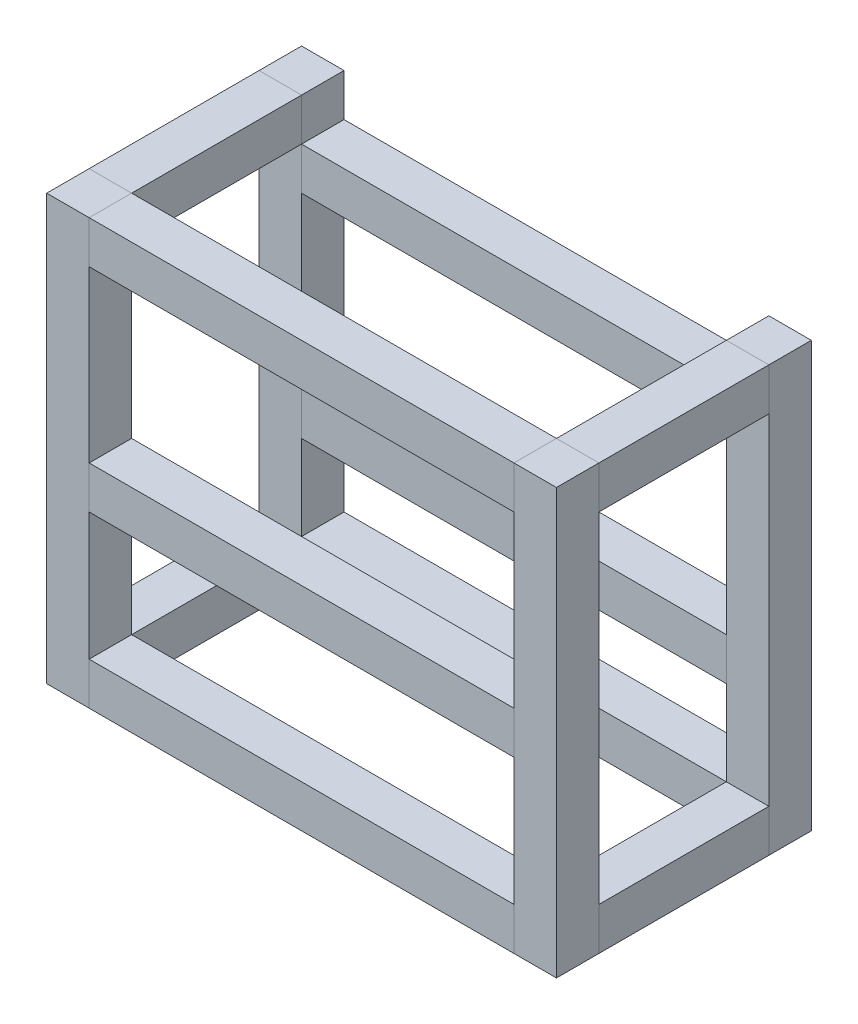
from build123d import *

# Parameters (mm, degrees)
SKETCH1_W                  = 25.4
SKETCH1_H                  = 25.4
BOSS_EXTRUDE1_DEPTH        = 254
BOSS_EXTRUDE1_2_DEPTH      = 254
BOSS_EXTRUDE1_3_DEPTH      = 254
BOSS_EXTRUDE1_4_DEPTH      = 254
SKETCH2_W                  = 25.4
SKETCH2_H                  = 25.4
BOSS_EXTRUDE2_DEPTH        = 127
BOSS_EXTRUDE2_DEPTH_BACK   = 127
BOSS_EXTRUDE2_2_DEPTH      = 127
BOSS_EXTRUDE2_2_DEPTH_BACK = 127
BOSS_EXTRUDE2_3_DEPTH      = 127
BOSS_EXTRUDE2_3_DEPTH_BACK = 127
BOSS_EXTRUDE2_4_DEPTH      = 127
BOSS_EXTRUDE2_4_DEPTH_BACK = 127
BOSS_EXTRUDE2_5_DEPTH      = 127
BOSS_EXTRUDE2_5_DEPTH_BACK = 127
BOSS_EXTRUDE2_6_DEPTH      = 127
BOSS_EXTRUDE2_6_DEPTH_BACK = 127
SKETCH3_W                  = 25.4
SKETCH3_H                  = 25.4
BOSS_EXTRUDE3_DEPTH        = 50.8
BOSS_EXTRUDE3_DEPTH_BACK   = 50.8
BOSS_EXTRUDE3_2_DEPTH      = 50.8
BOSS_EXTRUDE3_2_DEPTH_BACK = 50.8
BOSS_EXTRUDE3_3_DEPTH      = 50.8
BOSS_EXTRUDE3_3_DEPTH_BACK = 50.8
BOSS_EXTRUDE3_4_DEPTH      = 50.8
BOSS_EXTRUDE3_4_DEPTH_BACK = 50.8


with BuildPart() as part:
    # Sketch1 → Boss-Extrude1 (new body)
    with BuildSketch(Plane(origin=(0, 0, 0), x_dir=(1, 0, 0), z_dir=(0, 1, 0))):
        with Locations((-139.7, 63.5)):
            Rectangle(SKETCH1_W, SKETCH1_H)
    extrude(amount=BOSS_EXTRUDE1_DEPTH)


with BuildPart() as body_2:
    # Sketch1 → Boss-Extrude1 2 (new body)
    with BuildSketch(Plane(origin=(0, 0, 0), x_dir=(1, 0, 0), z_dir=(0, 1, 0))):
        with Locations((-139.7, -63.5)):
            Rectangle(SKETCH1_W, SKETCH1_H)
    extrude(amount=BOSS_EXTRUDE1_2_DEPTH)


with BuildPart() as body_3:
    # Sketch1 → Boss-Extrude1 3 (new body)
    with BuildSketch(Plane(origin=(0, 0, 0), x_dir=(1, 0, 0), z_dir=(0, 1, 0))):
        with Locations((139.7, -63.5)):
            Rectangle(SKETCH1_W, SKETCH1_H)
    extrude(amount=BOSS_EXTRUDE1_3_DEPTH)


with BuildPart() as body_4:
    # Sketch1 → Boss-Extrude1 4 (new body)
    with BuildSketch(Plane(origin=(0, 0, 0), x_dir=(1, 0, 0), z_dir=(0, 1, 0))):
        with Locations((139.7, 63.5)):
            Rectangle(SKETCH1_W, SKETCH1_H)
    extrude(amount=BOSS_EXTRUDE1_4_DEPTH)


with BuildPart() as body_5:
    # Sketch2 → Boss-Extrude2 (new body, two sides)
    with BuildSketch(Plane(origin=(0, 0, 0), x_dir=(0, 0, -1), z_dir=(1, 0, 0))) as boss_extrude2_sk:
        with Locations((-63.5, 241.3)):
            Rectangle(SKETCH2_W, SKETCH2_H)
    extrude(amount=BOSS_EXTRUDE2_DEPTH)
    extrude(boss_extrude2_sk.sketch, amount=-BOSS_EXTRUDE2_DEPTH_BACK)


with BuildPart() as body_6:
    # Sketch2 → Boss-Extrude2 2 (new body, two sides)
    with BuildSketch(Plane(origin=(0, 0, 0), x_dir=(0, 0, -1), z_dir=(1, 0, 0))) as boss_extrude2_2_sk:
        with Locations((63.5, 215.9)):
            Rectangle(SKETCH2_W, SKETCH2_H)
    extrude(amount=BOSS_EXTRUDE2_2_DEPTH)
    extrude(boss_extrude2_2_sk.sketch, amount=-BOSS_EXTRUDE2_2_DEPTH_BACK)


with BuildPart() as body_7:
    # Sketch2 → Boss-Extrude2 3 (new body, two sides)
    with BuildSketch(Plane(origin=(0, 0, 0), x_dir=(0, 0, -1), z_dir=(1, 0, 0))) as boss_extrude2_3_sk:
        with Locations((-63.5, 12.7)):
            Rectangle(SKETCH2_W, SKETCH2_H)
    extrude(amount=BOSS_EXTRUDE2_3_DEPTH)
    extrude(boss_extrude2_3_sk.sketch, amount=-BOSS_EXTRUDE2_3_DEPTH_BACK)


with BuildPart() as body_8:
    # Sketch2 → Boss-Extrude2 4 (new body, two sides)
    with BuildSketch(Plane(origin=(0, 0, 0), x_dir=(0, 0, -1), z_dir=(1, 0, 0))) as boss_extrude2_4_sk:
        with Locations((63.5, 12.7)):
            Rectangle(SKETCH2_W, SKETCH2_H)
    extrude(amount=BOSS_EXTRUDE2_4_DEPTH)
    extrude(boss_extrude2_4_sk.sketch, amount=-BOSS_EXTRUDE2_4_DEPTH_BACK)


with BuildPart() as body_9:
    # Sketch2 → Boss-Extrude2 5 (new body, two sides)
    with BuildSketch(Plane(origin=(0, 0, 0), x_dir=(0, 0, -1), z_dir=(1, 0, 0))) as boss_extrude2_5_sk:
        with Locations((-63.5, 114.3)):
            Rectangle(SKETCH2_W, SKETCH2_H)
    extrude(amount=BOSS_EXTRUDE2_5_DEPTH)
    extrude(boss_extrude2_5_sk.sketch, amount=-BOSS_EXTRUDE2_5_DEPTH_BACK)


with BuildPart() as body_10:
    # Sketch2 → Boss-Extrude2 6 (new body, two sides)
    with BuildSketch(Plane(origin=(0, 0, 0), x_dir=(0, 0, -1), z_dir=(1, 0, 0))) as boss_extrude2_6_sk:
        with Locations((63.5, 88.9)):
            Rectangle(SKETCH2_W, SKETCH2_H)
    extrude(amount=BOSS_EXTRUDE2_6_DEPTH)
    extrude(boss_extrude2_6_sk.sketch, amount=-BOSS_EXTRUDE2_6_DEPTH_BACK)


with BuildPart() as body_11:
    # Sketch3 → Boss-Extrude3 (new body, two sides)
    with BuildSketch(Plane.XY) as boss_extrude3_sk:
        with Locations((-139.7, 241.3)):
            Rectangle(SKETCH3_W, SKETCH3_H)
    extrude(amount=BOSS_EXTRUDE3_DEPTH)
    extrude(boss_extrude3_sk.sketch, amount=-BOSS_EXTRUDE3_DEPTH_BACK)


with BuildPart() as body_12:
    # Sketch3 → Boss-Extrude3 2 (new body, two sides)
    with BuildSketch(Plane.XY) as boss_extrude3_2_sk:
        with Locations((-139.7, 12.7)):
            Rectangle(SKETCH3_W, SKETCH3_H)
    extrude(amount=BOSS_EXTRUDE3_2_DEPTH)
    extrude(boss_extrude3_2_sk.sketch, amount=-BOSS_EXTRUDE3_2_DEPTH_BACK)


with BuildPart() as body_13:
    # Sketch3 → Boss-Extrude3 3 (new body, two sides)
    with BuildSketch(Plane.XY) as boss_extrude3_3_sk:
        with Locations((139.7, 241.3)):
            Rectangle(SKETCH3_W, SKETCH3_H)
    extrude(amount=BOSS_EXTRUDE3_3_DEPTH)
    extrude(boss_extrude3_3_sk.sketch, amount=-BOSS_EXTRUDE3_3_DEPTH_BACK)


with BuildPart() as body_14:
    # Sketch3 → Boss-Extrude3 4 (new body, two sides)
    with BuildSketch(Plane.XY) as boss_extrude3_4_sk:
        with Locations((139.7, 12.7)):
            Rectangle(SKETCH3_W, SKETCH3_H)
    extrude(amount=BOSS_EXTRUDE3_4_DEPTH)
    extrude(boss_extrude3_4_sk.sketch, amount=-BOSS_EXTRUDE3_4_DEPTH_BACK)


solid = Compound([part.part, body_2.part, body_3.part, body_4.part, body_5.part, body_6.part, body_7.part, body_8.part, body_9.part, body_10.part, body_11.part, body_12.part, body_13.part, body_14.part])
